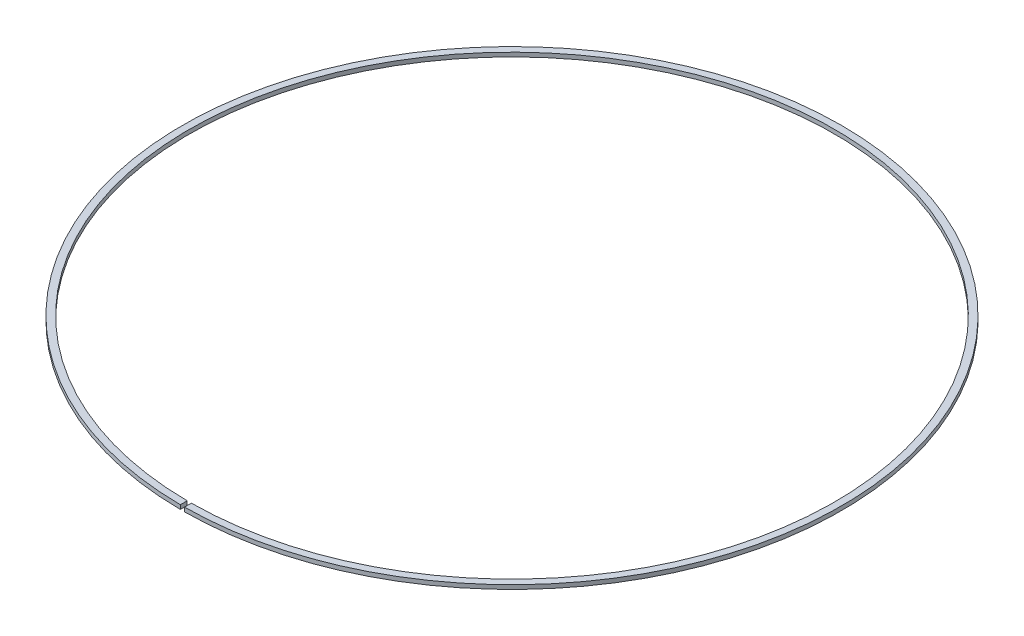
from build123d import *

# Parameters (mm, degrees)
SKETCH1_R           = 240
SKETCH1_R_2         = 235
BOSS_EXTRUDE1_DEPTH = 3
SKETCH2_W           = 3
SKETCH2_H           = 6.529330519
CUT_EXTRUDE1_DEPTH  = 3


with BuildPart() as part:
    # Sketch1 → Boss-Extrude1 (new body)
    with BuildSketch(Plane(origin=(0, 0, 0), x_dir=(1, 0, 0), z_dir=(0, 1, 0))):
        Circle(SKETCH1_R)
        Circle(SKETCH1_R_2, mode=Mode.SUBTRACT)
    extrude(amount=BOSS_EXTRUDE1_DEPTH)

    # Sketch2 → Cut-Extrude1 (cut)
    with BuildSketch(Plane(origin=(0, 3, 0), x_dir=(1, 0, 0), z_dir=(0, 1, 0))):
        with Locations((0, -237.335841941)):
            Rectangle(SKETCH2_W, SKETCH2_H)
    extrude(amount=-CUT_EXTRUDE1_DEPTH, mode=Mode.SUBTRACT)


solid = part.part
